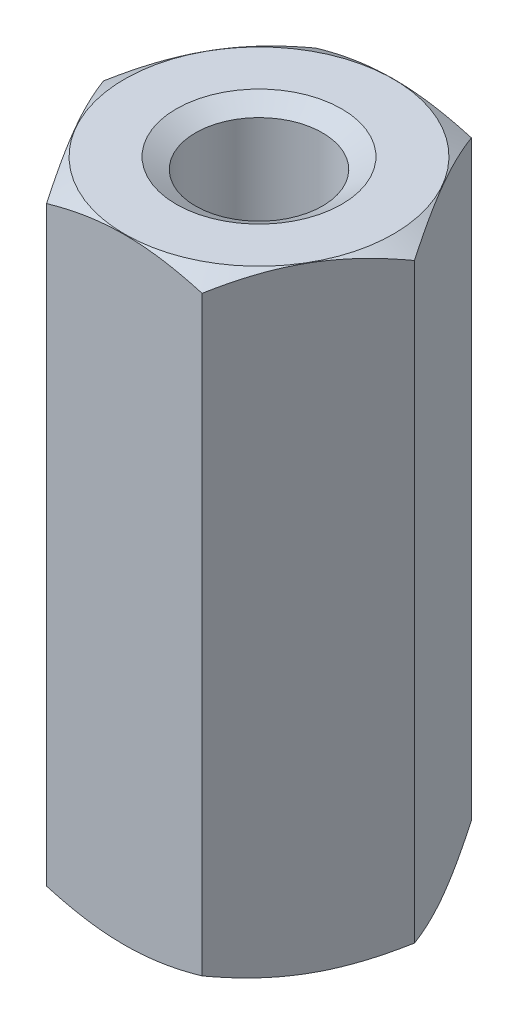
from build123d import *

# Parameters (mm, degrees)
SKETCH1_R             = 4.041451884
SKETCH1_R_2           = 1.65
BOSS_EXTRUDE1_DEPTH   = 16
CHAMFER1_SIZE         = 0.55
CHAMFER1_SIZE2        = 0.317542648
CHAMFER2_SIZE         = 0.55
CHAMFER2_SIZE2        = 0.317542648
SKETCH2_OUTSIDE_W     = 14.014
SKETCH2_OUTSIDE_H     = 14.014
CUT_EXTRUDE1_DEPTH    = 17
CHAMFER3_SIZE         = 0.5
CHAMFER3_SIZE2        = 0.288675135
CHAMFER3_PART_2_SIZE  = 0.5
CHAMFER3_PART_2_SIZE2 = 0.288675135


with BuildPart() as part:
    # Sketch1 → Boss-Extrude1 (new body)
    with BuildSketch(Plane(origin=(0, 0, 0), x_dir=(1, 0, 0), z_dir=(0, 1, 0))):
        Circle(SKETCH1_R)
        Circle(SKETCH1_R_2, mode=Mode.SUBTRACT)
    extrude(amount=BOSS_EXTRUDE1_DEPTH)

    # Chamfer1
    chamfer1_edges = [part.edges().sort_by_distance(p)[0] for p in [
        (-4.041451884, 16, 0),
    ]]
    chamfer1_side = [part.faces().sort_by_distance(p)[0] for p in [
        (-3.927142363, 16, 0),
    ]]
    chamfer(chamfer1_edges, length=CHAMFER1_SIZE, length2=CHAMFER1_SIZE2, reference=chamfer1_side[0])

    # Chamfer2
    chamfer2_edges = [part.edges().sort_by_distance(p)[0] for p in [
        (-4.041451884, 0, 0),
    ]]
    chamfer2_side = [part.faces().sort_by_distance(p)[0] for p in [
        (-3.927142363, 0, 0),
    ]]
    chamfer(chamfer2_edges, length=CHAMFER2_SIZE, length2=CHAMFER2_SIZE2, reference=chamfer2_side[0])

    # Sketch2 outside → Cut-Extrude1 (cut, through all)
    with BuildSketch(Plane.XZ):
        Rectangle(SKETCH2_OUTSIDE_W, SKETCH2_OUTSIDE_H)
        Polygon((4.041451884, 0), (2.020725942, -3.5), (-2.020725942, -3.5), (-4.041451884, 0), (-2.020725942, 3.5), (2.020725942, 3.5), align=None, mode=Mode.SUBTRACT)
    extrude(amount=-CUT_EXTRUDE1_DEPTH, mode=Mode.SUBTRACT)

    # Chamfer3
    chamfer3_edges = [part.edges().sort_by_distance(p)[0] for p in [
        (-1.65, 0, 0),
    ]]
    chamfer3_side = [part.faces().sort_by_distance(p)[0] for p in [
        (-1.65, 8, 0),
    ]]
    chamfer(chamfer3_edges, length=CHAMFER3_SIZE, length2=CHAMFER3_SIZE2, reference=chamfer3_side[0])

    # Chamfer3 part 2
    chamfer3_part_2_edges = [part.edges().sort_by_distance(p)[0] for p in [
        (-1.65, 16, 0),
    ]]
    chamfer3_part_2_side = [part.faces().sort_by_distance(p)[0] for p in [
        (-3.392698712, 16, 0),
    ]]
    chamfer(chamfer3_part_2_edges, length=CHAMFER3_PART_2_SIZE, length2=CHAMFER3_PART_2_SIZE2, reference=chamfer3_part_2_side[0])


solid = part.part
